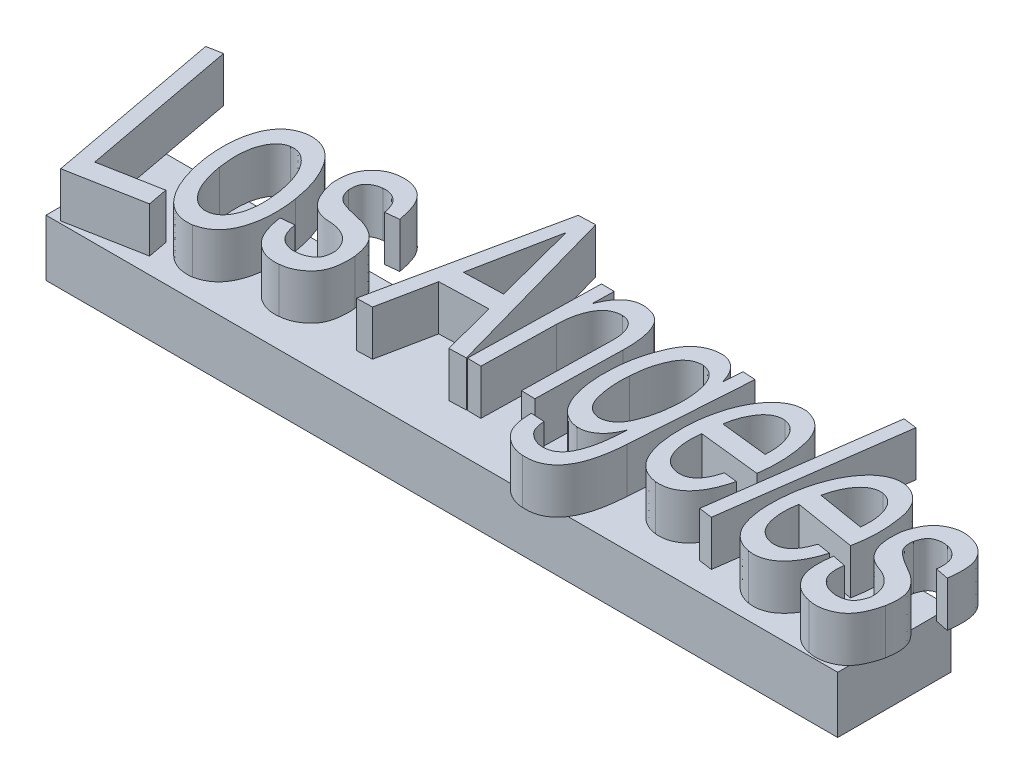
from build123d import *

# Parameters (mm, degrees)
SKETCH1_W           = 88.9
SKETCH1_H           = 12.7
BOSS_EXTRUDE1_DEPTH = 6.35
BOSS_EXTRUDE2_DEPTH = 5.08


with BuildPart() as part:
    # Sketch1 → Boss-Extrude1 (new body)
    with BuildSketch(Plane(origin=(0, 0, 0), x_dir=(1, 0, 0), z_dir=(0, 1, 0))):
        with Locations((44.45, 6.35)):
            Rectangle(SKETCH1_W, SKETCH1_H)
    extrude(amount=BOSS_EXTRUDE1_DEPTH)

    # Sketch4 → Boss-Extrude2 (add)
    with BuildSketch(Plane(origin=(0, 6.35, 0), x_dir=(1, 0, 0), z_dir=(0, 1, 0))):
        Polygon((1.386739329, 0.25954173), (9.796068852, 1.833429402), (9.375962144, 4.077870459), (2.65561001, 2.820091305), (-0.673735645, 20.607286681), (-2.362713034, 20.291178163), align=None)
        with BuildLine():
            add(Edge.make_bspline(
                [(8.537018372, 9.101471274), (8.580799578, 8.834320745), (8.666447796, 8.31169999), (8.847978922, 7.555307868), (9.051668328, 6.840317669), (9.289932152, 6.166912473), (9.550753664, 5.532172303), (9.845524704, 4.939235761), (10.167081842, 4.386690498), (10.520819993, 3.881278636), (10.896307583, 3.424870796), (11.303272628, 3.036955632), (11.734813452, 2.719638512), (12.189889779, 2.474247196), (12.664929288, 2.290790647), (13.167250147, 2.191205733), (13.691001629, 2.149725881), (14.044738343, 2.18151254), (14.224987313, 2.197709651)],
                knots=[0, 0, 0, 0, 0.000811887, 0.001588276, 0.002332023, 0.003041304, 0.003730075, 0.004389466, 0.005026263, 0.005646119, 0.006238379, 0.006796368, 0.007328364, 0.00784026, 0.00834347, 0.008849721, 0.009371437, 0.009913485, 0.009913485, 0.009913485, 0.009913485], degree=3))
            add(Edge.make_bspline(
                [(14.224987313, 2.197709651), (14.401125566, 2.238615432), (14.746515731, 2.318827733), (15.234624609, 2.514433546), (15.675164513, 2.774797862), (16.078257795, 3.085529274), (16.431758706, 3.463957708), (16.741076432, 3.899501531), (17.007630648, 4.393659111), (17.226282332, 4.94235401), (17.407090604, 5.533746991), (17.540687208, 6.160346336), (17.640931937, 6.81520532), (17.698856765, 7.49958692), (17.707877452, 8.214054017), (17.683727802, 8.95702645), (17.618060118, 9.730543059), (17.542728571, 10.253072523), (17.504271866, 10.519823472)],
                knots=[0, 0, 0, 0, 0.000541938, 0.001062689, 0.001569866, 0.002073007, 0.002584287, 0.003117212, 0.003671628, 0.004264478, 0.004886354, 0.005524715, 0.006184754, 0.006872781, 0.007583263, 0.008327091, 0.009102238, 0.009910637, 0.009910637, 0.009910637, 0.009910637], degree=3))
            add(Edge.make_bspline(
                [(17.504271866, 10.519823472), (17.456823974, 10.787305056), (17.363991272, 11.310637856), (17.191976714, 12.07259722), (16.98473705, 12.791799565), (16.750818205, 13.469505457), (16.485800101, 14.106069918), (16.189059262, 14.698624165), (15.865596927, 15.253390939), (15.514341043, 15.761892029), (15.137612559, 16.218948052), (14.729377432, 16.606467195), (14.301031271, 16.927207194), (13.846205173, 17.175498318), (13.369958116, 17.356089757), (12.866697955, 17.45679034), (12.342856636, 17.498034299), (11.989132376, 17.466280341), (11.808889752, 17.450099895)],
                knots=[0, 0, 0, 0, 0.000814914, 0.001594395, 0.002342111, 0.003059189, 0.003744148, 0.004409078, 0.005045874, 0.00566912, 0.00626138, 0.006819369, 0.007353812, 0.00786208, 0.008369156, 0.008875407, 0.009397123, 0.009939172, 0.009939172, 0.009939172, 0.009939172], degree=3))
            add(Edge.make_bspline(
                [(11.808889752, 17.450099895), (11.632757506, 17.409188869), (11.287379122, 17.328966285), (10.799185272, 17.133434646), (10.358956668, 16.872798587), (9.953909129, 16.562462161), (9.605102346, 16.18005007), (9.289872587, 15.747446719), (9.028157167, 15.250407323), (8.805666276, 14.702368387), (8.634065382, 14.108404586), (8.489458897, 13.483199283), (8.399522524, 12.825101673), (8.338359435, 12.138701767), (8.330359914, 11.421333697), (8.354171961, 10.674273143), (8.420224429, 9.89528425), (8.495312921, 9.368584707), (8.53373528, 9.099075504)],
                knots=[0, 0, 0, 0, 0.000541938, 0.001062689, 0.001569866, 0.002073007, 0.002587298, 0.003116867, 0.003674917, 0.004267767, 0.004888449, 0.005527705, 0.006191223, 0.00687925, 0.007593861, 0.008341817, 0.009121079, 0.009937666, 0.009937666, 0.009937666, 0.009937666], degree=3))
            Line((8.53373528, 9.099075504), (8.537018372, 9.101471274))
        make_face()
        with BuildLine():
            add(Edge.make_bspline(
                [(10.144725118, 9.356294064), (10.115424233, 9.571843136), (10.058571206, 9.990076817), (10.003400079, 10.602837522), (9.983466045, 11.181840408), (9.989089233, 11.727983562), (10.030490437, 12.239801485), (10.100396285, 12.717260011), (10.196764032, 13.160412308), (10.329762369, 13.56609616), (10.487294065, 13.932125168), (10.656812235, 14.263213791), (10.859676787, 14.544544865), (11.07173936, 14.792406637), (11.311032357, 14.993412167), (11.568915746, 15.150834977), (11.846457399, 15.271874008), (12.043302509, 15.314047188), (12.143426337, 15.335498269)],
                knots=[0, 0, 0, 0, 0.000652551, 0.001266157, 0.001844737, 0.00238997, 0.002903763, 0.003383884, 0.003836783, 0.004262562, 0.004662242, 0.005031763, 0.005375529, 0.005700338, 0.006008105, 0.006308439, 0.00660454, 0.006911058, 0.006911058, 0.006911058, 0.006911058], degree=3))
            add(Edge.make_bspline(
                [(12.143426337, 15.335498269), (12.245204215, 15.345613133), (12.446126407, 15.365581133), (12.747598151, 15.339006209), (13.04179347, 15.266063017), (13.332375543, 15.152630927), (13.610073245, 14.979353488), (13.889968181, 14.774744796), (14.1570157, 14.514960118), (14.417483808, 14.211812939), (14.667237453, 13.867237589), (14.902590435, 13.479158377), (15.106688134, 13.04380083), (15.310941271, 12.573299008), (15.477243216, 12.054835264), (15.643176883, 11.498979824), (15.781020922, 10.898512043), (15.855406369, 10.481612546), (15.893540159, 10.267888512)],
                knots=[0, 0, 0, 0, 0.000306323, 0.000604719, 0.000902229, 0.001213605, 0.001535884, 0.00188116, 0.002252155, 0.002650403, 0.003079156, 0.003527512, 0.004009619, 0.004520482, 0.005065104, 0.005641499, 0.006260625, 0.006911896, 0.006911896, 0.006911896, 0.006911896], degree=3))
            add(Edge.make_bspline(
                [(15.893540159, 10.267888512), (15.922721417, 10.051950818), (15.979295668, 9.633308364), (16.034642706, 9.020194052), (16.05450007, 8.441190379), (16.049052011, 7.896409973), (16.007491208, 7.387351109), (15.93775907, 6.913962096), (15.840529302, 6.473795491), (15.708926956, 6.070465603), (15.550708607, 5.705169042), (15.376224949, 5.377615372), (15.175853231, 5.0950148), (14.960673379, 4.851092889), (14.722826965, 4.65060892), (14.465016352, 4.490675184), (14.184493125, 4.378571897), (13.988917646, 4.334500183), (13.890450728, 4.312311277)],
                knots=[0, 0, 0, 0, 0.000653663, 0.001267268, 0.001845848, 0.002391082, 0.002900758, 0.003376793, 0.003825663, 0.004251442, 0.004647327, 0.005018805, 0.005362571, 0.005684293, 0.005992061, 0.006292394, 0.006590734, 0.006893246, 0.006893246, 0.006893246, 0.006893246], degree=3))
            add(Edge.make_bspline(
                [(13.890450728, 4.312311277), (13.788661924, 4.302173804), (13.587718161, 4.282161171), (13.286404831, 4.30906388), (12.992848053, 4.380450017), (12.705298848, 4.498257637), (12.422905563, 4.661843184), (12.145520782, 4.869539927), (11.876755457, 5.12413061), (11.616314329, 5.422429956), (11.369697649, 5.765766649), (11.137600081, 6.152453528), (10.923918117, 6.581974729), (10.729849526, 7.054172243), (10.558474658, 7.570160925), (10.396563957, 8.12592547), (10.256185072, 8.725684611), (10.182408665, 9.141364823), (10.144466988, 9.355140545)],
                knots=[0, 0, 0, 0, 0.000306323, 0.000604719, 0.000902229, 0.001209774, 0.001533531, 0.001878807, 0.002246964, 0.002642094, 0.00306508, 0.003513436, 0.003993664, 0.004502938, 0.005043648, 0.005624009, 0.006239114, 0.006890384, 0.006890384, 0.006890384, 0.006890384], degree=3))
            Line((10.144466988, 9.355140545), (10.144725118, 9.356294064))
        make_face(mode=Mode.SUBTRACT)
        with BuildLine():
            add(Edge.make_bspline(
                [(18.480618725, 7.789259508), (18.514447486, 7.573125068), (18.579785704, 7.155674381), (18.72201519, 6.560937906), (18.885181034, 6.017904033), (19.075660632, 5.527613752), (19.289073156, 5.086043585), (19.532562741, 4.696733965), (19.802266343, 4.356310781), (20.101955019, 4.072193989), (20.416974796, 3.830615765), (20.747217038, 3.6328458), (21.083210678, 3.463901632), (21.437354154, 3.345730711), (21.798868553, 3.256577269), (22.173193086, 3.213229975), (22.557856552, 3.203164359), (22.816139767, 3.227282009), (22.948184941, 3.23961196)],
                knots=[0, 0, 0, 0, 0.000656064, 0.001267149, 0.00183285, 0.002355921, 0.00284355, 0.003301915, 0.003730847, 0.004142718, 0.004537568, 0.004919349, 0.005296161, 0.005663181, 0.006036833, 0.006411307, 0.006791364, 0.007188904, 0.007188904, 0.007188904, 0.007188904], degree=3))
            add(Edge.make_bspline(
                [(22.948184941, 3.23961196), (23.071101109, 3.252201794), (23.313397777, 3.277019318), (23.668528044, 3.358559573), (24.01169392, 3.469519847), (24.342993405, 3.613735163), (24.65957016, 3.794784187), (24.964185145, 4.004047476), (25.256562564, 4.247901875), (25.537116334, 4.520666883), (25.7915311, 4.835101739), (26.005358786, 5.196263273), (26.171803753, 5.605033739), (26.305433569, 6.055546722), (26.388640317, 6.552101759), (26.436718112, 7.091810654), (26.451455313, 7.677233272), (26.423601665, 8.081549853), (26.409193071, 8.290701391)],
                knots=[0, 0, 0, 0, 0.000370374, 0.000730094, 0.001090573, 0.001451217, 0.00181186, 0.00218304, 0.002558491, 0.002952757, 0.003355244, 0.00376819, 0.004206932, 0.00467611, 0.005175184, 0.005714377, 0.00630098, 0.006929621, 0.006929621, 0.006929621, 0.006929621], degree=3))
            add(Edge.make_bspline(
                [(26.409193071, 8.290701391), (26.384824053, 8.454822836), (26.337687503, 8.772279963), (26.24037782, 9.227133472), (26.115148695, 9.64196516), (25.973108006, 10.019503255), (25.804095004, 10.356891395), (25.608054059, 10.652019545), (25.393236168, 10.911210013), (25.077993354, 11.200895937), (24.647268912, 11.495249326), (24.100575792, 11.783308702), (23.525702226, 12.006605128), (23.124457728, 12.09542954), (22.923404453, 12.139937163)],
                knots=[0, 0, 0, 0, 0.000497705, 0.000962701, 0.001393894, 0.001796572, 0.002171523, 0.002523187, 0.002857392, 0.003178849, 0.003804458, 0.004415961, 0.005030358, 0.005647401, 0.005647401, 0.005647401, 0.005647401], degree=3))
            add(Edge.make_bspline(
                [(22.923404453, 12.139937163), (22.551723196, 12.22072127), (21.826511443, 12.378344456), (21.034867613, 12.629908345), (20.550480102, 12.851880694), (20.341443846, 12.992649272), (20.154868509, 13.157440629), (19.993047077, 13.34688821), (19.860476523, 13.567294949), (19.748817081, 13.809044519), (19.666137577, 14.079060158), (19.629909037, 14.267900961), (19.61107925, 14.366050984)],
                knots=[0, 0, 0, 0, 0.001141054, 0.002226386, 0.002483149, 0.0027363, 0.002979133, 0.003228208, 0.00348038, 0.003748359, 0.00402529, 0.004324998, 0.004324998, 0.004324998, 0.004324998], degree=3))
            add(Edge.make_bspline(
                [(19.61107925, 14.366050984), (19.60421998, 14.535734016), (19.591454733, 14.851517751), (19.673860631, 15.291197949), (19.832726861, 15.660786375), (20.089490199, 15.936205371), (20.384281072, 16.143626732), (20.700437052, 16.302702642), (21.038099684, 16.409958432), (21.272019302, 16.437643335), (21.39114429, 16.451742041)],
                knots=[0, 0, 0, 0, 0.000508, 0.000945399, 0.001331644, 0.001697267, 0.002058313, 0.002409248, 0.002755412, 0.003114634, 0.003114634, 0.003114634, 0.003114634], degree=3))
            add(Edge.make_bspline(
                [(21.39114429, 16.451742041), (21.517849582, 16.46247575), (21.771237751, 16.483941268), (22.152569608, 16.421722249), (22.522372215, 16.285174816), (22.817207877, 16.115047419), (23.039420562, 15.938223739), (23.194789181, 15.774987557), (23.330051169, 15.580422542), (23.459503331, 15.362610042), (23.56936095, 15.113851688), (23.663929477, 14.838458615), (23.746836124, 14.536327544), (23.789311896, 14.323678486), (23.811371933, 14.213237976)],
                knots=[0, 0, 0, 0, 0.000380326, 0.000760586, 0.001147317, 0.001558171, 0.001775541, 0.001997569, 0.002231384, 0.002484972, 0.002756711, 0.003045374, 0.003357981, 0.003695765, 0.003695765, 0.003695765, 0.003695765], degree=3))
            Line((23.811371933, 14.213237976), (25.343394132, 14.379562481))
            add(Edge.make_bspline(
                [(25.343394132, 14.379562481), (25.305792163, 14.588902955), (25.233355199, 14.992179411), (25.092771659, 15.566873119), (24.93289188, 16.088805275), (24.752509921, 16.558226648), (24.548320542, 16.973978404), (24.313766785, 17.331952861), (24.063443389, 17.642967834), (23.782744524, 17.895677099), (23.4862031, 18.104525606), (23.174607459, 18.273647948), (22.850968647, 18.410624058), (22.515219317, 18.515618396), (22.164419691, 18.580501658), (21.800822284, 18.614308473), (21.421737333, 18.60944233), (21.166567153, 18.580935169), (21.035957299, 18.566343667)],
                knots=[0, 0, 0, 0, 0.00063795, 0.001228956, 0.001773704, 0.002274535, 0.002736292, 0.003160144, 0.003556223, 0.003930445, 0.004289097, 0.004642116, 0.004991908, 0.005342016, 0.00569518, 0.006060126, 0.006435986, 0.006830101, 0.006830101, 0.006830101, 0.006830101], degree=3))
            add(Edge.make_bspline(
                [(21.035957299, 18.566343667), (20.929591546, 18.553327039), (20.719080865, 18.52756556), (20.4102277, 18.451570663), (20.111963249, 18.344850177), (19.825805253, 18.201569633), (19.548765309, 18.032597829), (19.28208091, 17.833318881), (19.029845616, 17.598757805), (18.787320969, 17.33798781), (18.564537847, 17.043503727), (18.381223513, 16.71126259), (18.225237729, 16.348447931), (18.110632429, 15.948732045), (18.034718097, 15.513907088), (17.988881937, 15.045887024), (17.981926757, 14.544622189), (18.002247495, 14.200765398), (18.012737786, 14.023254236)],
                knots=[0, 0, 0, 0, 0.000321245, 0.000635783, 0.000951943, 0.001269637, 0.001594052, 0.001924459, 0.002266459, 0.002625965, 0.002991892, 0.003370983, 0.003761445, 0.004174453, 0.004615154, 0.005084059, 0.005583867, 0.006117224, 0.006117224, 0.006117224, 0.006117224], degree=3))
            add(Edge.make_bspline(
                [(18.012737786, 14.023254236), (18.047341959, 13.871536398), (18.114705366, 13.576189627), (18.23256754, 13.150516548), (18.371459955, 12.756122265), (18.517890182, 12.38778084), (18.682744962, 12.047640755), (18.866690563, 11.737685783), (19.057419217, 11.450693992), (19.270609227, 11.198719834), (19.493743557, 10.972346184), (19.73615953, 10.777856966), (19.990297844, 10.607487992), (20.262448925, 10.469733641), (20.549871351, 10.36338683), (20.850377968, 10.278813008), (21.168102344, 10.230589098), (21.597833375, 10.204852212), (22.119532919, 10.175579436), (22.702707093, 10.051053182), (23.223604259, 9.856995644), (23.680811456, 9.59075717), (24.074273182, 9.250588013), (24.392125393, 8.832956909), (24.656399489, 8.351142379), (24.766267183, 7.993135426), (24.823241851, 7.807481879)],
                knots=[0, 0, 0, 0, 0.000466827, 0.000908765, 0.001324121, 0.00172063, 0.002097442, 0.002456569, 0.002801375, 0.003129762, 0.003445166, 0.003753487, 0.004060478, 0.004361549, 0.004666085, 0.004978691, 0.005296466, 0.0056278, 0.006270211, 0.006861548, 0.007409232, 0.007931275, 0.008440633, 0.008958625, 0.009498213, 0.010079441, 0.010079441, 0.010079441, 0.010079441], degree=3))
            add(Edge.make_bspline(
                [(24.823241851, 7.807481879), (24.829146477, 7.698770393), (24.840433323, 7.490965541), (24.828668834, 7.190816541), (24.790396807, 6.9175959), (24.736959863, 6.667469258), (24.647490561, 6.446584158), (24.539789498, 6.250917377), (24.412668257, 6.075675368), (24.200315922, 5.89582241), (23.919534849, 5.707302928), (23.562828748, 5.537815388), (23.193135856, 5.419734667), (22.939369065, 5.392616547), (22.811892258, 5.378994074)],
                knots=[0, 0, 0, 0, 0.000326512, 0.000624135, 0.000899244, 0.001153705, 0.001389156, 0.001610991, 0.001823279, 0.002033873, 0.002441665, 0.002835151, 0.003215321, 0.003599063, 0.003599063, 0.003599063, 0.003599063], degree=3))
            add(Edge.make_bspline(
                [(22.811892258, 5.378994074), (22.654898547, 5.365805063), (22.344972601, 5.339768246), (21.884512956, 5.410749554), (21.446434396, 5.562484693), (21.103626503, 5.756735857), (20.852635237, 5.963165453), (20.677482336, 6.151733171), (20.519339209, 6.371676197), (20.385216598, 6.628071396), (20.259240566, 6.912310723), (20.159334291, 7.231784156), (20.070977442, 7.580452228), (20.02924229, 7.825018655), (20.007567055, 7.952034724)],
                knots=[0, 0, 0, 0, 0.000471282, 0.000930372, 0.001384906, 0.001856712, 0.002103137, 0.002357363, 0.002626706, 0.002913145, 0.003223891, 0.003558249, 0.003915853, 0.004302253, 0.004302253, 0.004302253, 0.004302253], degree=3))
            Line((20.007567055, 7.952034724), (18.480618725, 7.789259508))
        make_face()
        Polygon((30.572750052, 4.267429982), (32.344312933, 4.323161879), (33.597978139, 10.501182713), (39.05728416, 10.672927949), (40.659812171, 4.584760584), (42.557915258, 4.644473331), (36.875076653, 24.851497055), (34.976973566, 24.791784307), align=None)
        Polygon((35.957835609, 22.367208786), (35.993989953, 22.368346172), (38.443337895, 12.937737083), (34.068662209, 12.800113417), align=None, mode=Mode.SUBTRACT)
        with BuildLine():
            Line((42.641604646, 4.678149128), (44.178507116, 4.645923201))
            Line((44.178507116, 4.645923201), (44.352809454, 12.977103841))
            add(Edge.make_bspline(
                [(44.352809454, 12.977103841), (44.357147261, 13.141699553), (44.365636804, 13.46383062), (44.409154246, 13.93565161), (44.467183341, 14.38465269), (44.558078261, 14.807964468), (44.656796833, 15.209977491), (44.787859242, 15.584899555), (44.929790842, 15.939266754), (45.09972099, 16.264928047), (45.286960903, 16.560775685), (45.493570215, 16.822792419), (45.730060348, 17.039057847), (45.983020581, 17.222766121), (46.262734351, 17.358739507), (46.558035549, 17.465086528), (46.878475582, 17.527359184), (47.099677732, 17.534866029), (47.212830255, 17.538706039)],
                knots=[0, 0, 0, 0, 0.00049382, 0.000966457, 0.001420879, 0.001850982, 0.002264692, 0.002661739, 0.003041392, 0.003408992, 0.003761867, 0.004090824, 0.004406445, 0.00472044, 0.005025199, 0.005336082, 0.005660077, 0.005999372, 0.005999372, 0.005999372, 0.005999372], degree=3))
            add(Edge.make_bspline(
                [(47.212830255, 17.538706039), (47.35512533, 17.526167316), (47.631534881, 17.501810727), (48.011937155, 17.328640791), (48.341588861, 17.068235361), (48.608086094, 16.708534192), (48.817605614, 16.269262023), (48.964546245, 15.754479542), (49.044921883, 15.166491172), (49.048715019, 14.751155274), (49.050716434, 14.532006852)],
                knots=[0, 0, 0, 0, 0.000425799, 0.000827119, 0.001232835, 0.001674773, 0.002156879, 0.002686191, 0.003274361, 0.003931369, 0.003931369, 0.003931369, 0.003931369], degree=3))
            Line((49.050716434, 14.532006852), (48.843458145, 4.548108033))
            Line((48.843458145, 4.548108033), (50.380360616, 4.515882106))
            Line((50.380360616, 4.515882106), (50.583315393, 14.216571893))
            add(Edge.make_bspline(
                [(50.583315393, 14.216571893), (50.587694232, 14.41256896), (50.596226532, 14.794475172), (50.579703092, 15.354644846), (50.537260216, 15.886312821), (50.479482884, 16.390535911), (50.386279255, 16.862850564), (50.274468143, 17.306693326), (50.145844028, 17.724392142), (49.984968011, 18.109386315), (49.79597356, 18.45909533), (49.573039768, 18.769514726), (49.308526232, 19.031317944), (49.012910581, 19.254315916), (48.677797878, 19.429115986), (48.30677856, 19.554669843), (47.903712641, 19.644373537), (47.622195902, 19.663898567), (47.477155459, 19.673958071)],
                knots=[0, 0, 0, 0, 0.000588074, 0.001145879, 0.001680258, 0.002187922, 0.002667439, 0.00312321, 0.003560784, 0.003977288, 0.004372828, 0.004751176, 0.005119147, 0.005485074, 0.005858247, 0.006247483, 0.006657382, 0.007093003, 0.007093003, 0.007093003, 0.007093003], degree=3))
            add(Edge.make_bspline(
                [(47.477155459, 19.673958071), (47.311307654, 19.672129802), (46.985090635, 19.668533657), (46.510647443, 19.552056901), (46.068894165, 19.350798773), (45.662647504, 19.05766137), (45.289763827, 18.680944344), (44.949252662, 18.217987303), (44.639775198, 17.671214291), (44.471594935, 17.26678937), (44.383724564, 17.055486527)],
                knots=[0, 0, 0, 0, 0.000496229, 0.000976065, 0.001452889, 0.001944524, 0.002470198, 0.003036848, 0.003663872, 0.004349926, 0.004349926, 0.004349926, 0.004349926], degree=3))
            Line((44.383724564, 17.055486527), (44.347763817, 17.058995483))
            Line((44.347763817, 17.058995483), (44.396711734, 19.398573608))
            Line((44.396711734, 19.398573608), (42.950215291, 19.428903892))
            Line((42.950215291, 19.428903892), (42.641604646, 4.678149128))
        make_face()
        with BuildLine():
            Line((60.873845465, 18.740904129), (59.430252986, 18.836734921))
            Line((59.430252986, 18.836734921), (59.290273882, 16.729586801))
            Line((59.290273882, 16.729586801), (59.272228976, 16.730784686))
            add(Edge.make_bspline(
                [(59.272228976, 16.730784686), (59.209514223, 16.926428733), (59.089040889, 17.30225562), (58.855819873, 17.823208221), (58.573955434, 18.270138189), (58.250170141, 18.643746143), (57.888580004, 18.93719138), (57.503496232, 19.16393032), (57.08699806, 19.307287175), (56.798229961, 19.34384044), (56.652688612, 19.362263567)],
                knots=[0, 0, 0, 0, 0.000616089, 0.001183491, 0.0017071, 0.002195865, 0.00265965, 0.003098158, 0.003530477, 0.003969783, 0.003969783, 0.003969783, 0.003969783], degree=3))
            add(Edge.make_bspline(
                [(56.652688612, 19.362263567), (56.457980114, 19.355580684), (56.077595055, 19.342524916), (55.529761418, 19.227548795), (55.019202934, 19.046397876), (54.553716417, 18.78045194), (54.122929683, 18.447722556), (53.736694311, 18.036644739), (53.392004899, 17.552659847), (53.098063958, 16.999458366), (52.837699616, 16.407685653), (52.594113153, 15.799044845), (52.389531443, 15.176433028), (52.215085552, 14.540840292), (52.071380902, 13.892849635), (51.954690513, 13.231686217), (51.872042025, 12.557407361), (51.840502385, 12.10313314), (51.824623571, 11.874426169)],
                knots=[0, 0, 0, 0, 0.000583527, 0.001139985, 0.00167174, 0.002202468, 0.002741107, 0.003299096, 0.003888194, 0.00451842, 0.005174701, 0.005827371, 0.006484314, 0.007139592, 0.007803932, 0.008474788, 0.00915304, 0.009840732, 0.009840732, 0.009840732, 0.009840732], degree=3))
            add(Edge.make_bspline(
                [(51.824623571, 11.874426169), (51.811249978, 11.621184299), (51.784951097, 11.123189674), (51.786541933, 10.388618003), (51.81646171, 9.68256657), (51.889117161, 9.004593174), (51.988840743, 8.354243268), (52.130638267, 7.732510588), (52.304936505, 7.139606086), (52.506910479, 6.576736667), (52.747073279, 6.057062839), (53.028088571, 5.594066906), (53.347937051, 5.194877897), (53.701649029, 4.85254571), (54.098966926, 4.580479402), (54.528581777, 4.360097371), (54.999529721, 4.210939755), (55.328771897, 4.163114054), (55.496265848, 4.138783892)],
                knots=[0, 0, 0, 0, 0.000760653, 0.001495807, 0.002202824, 0.002879678, 0.003540349, 0.004175577, 0.004791125, 0.005393452, 0.005968068, 0.006505693, 0.007013961, 0.00749889, 0.007976642, 0.008453179, 0.00894299, 0.0094502, 0.0094502, 0.0094502, 0.0094502], degree=3))
            add(Edge.make_bspline(
                [(55.496265848, 4.138783892), (55.648182313, 4.136984683), (55.951191264, 4.133396025), (56.400896332, 4.235018056), (56.837932159, 4.41656584), (57.260033342, 4.683606976), (57.660621941, 5.036764987), (58.013422865, 5.486368816), (58.332716469, 6.016863949), (58.495912888, 6.413240268), (58.581436579, 6.620962754)],
                knots=[0, 0, 0, 0, 0.000454478, 0.000906491, 0.001371285, 0.001868613, 0.002398182, 0.002965148, 0.003576414, 0.004249465, 0.004249465, 0.004249465, 0.004249465], degree=3))
            Line((58.581436579, 6.620962754), (58.618752509, 6.620970821))
            Line((58.618752509, 6.620970821), (58.554437786, 5.652821684))
            add(Edge.make_bspline(
                [(58.554437786, 5.652821684), (58.538351652, 5.448174209), (58.50695664, 5.0487675), (58.443275185, 4.467375683), (58.354405351, 3.919528356), (58.254315171, 3.404532046), (58.129518561, 2.922020195), (57.985178885, 2.472814759), (57.82519282, 2.053747918), (57.645425796, 1.66985111), (57.443777657, 1.325784165), (57.221759526, 1.024269276), (56.972227021, 0.774044596), (56.699442014, 0.572089218), (56.403388105, 0.416071152), (56.08153785, 0.314906741), (55.739573999, 0.253371477), (55.504791069, 0.255446548), (55.384753653, 0.256507469)],
                knots=[0, 0, 0, 0, 0.000615835, 0.001201914, 0.00175394, 0.002280425, 0.002775277, 0.003248094, 0.003695251, 0.004120168, 0.004518244, 0.004889951, 0.0052404, 0.00557412, 0.005904785, 0.006239143, 0.00658271, 0.006942122, 0.006942122, 0.006942122, 0.006942122], degree=3))
            add(Edge.make_bspline(
                [(55.384753653, 0.256507469), (55.253005976, 0.26940362), (54.985258812, 0.295612112), (54.594356904, 0.430335294), (54.214784718, 0.633667575), (53.847526716, 0.896662975), (53.519767296, 1.243565841), (53.294005352, 1.693837611), (53.150084756, 2.223328782), (53.1341061, 2.605456003), (53.125599181, 2.808897713)],
                knots=[0, 0, 0, 0, 0.000396014, 0.000804809, 0.001229726, 0.001684898, 0.002155527, 0.002645077, 0.003180094, 0.003789236, 0.003789236, 0.003789236, 0.003789236], degree=3))
            Line((53.125599181, 2.808897713), (51.593782679, 2.911633486))
            add(Edge.make_bspline(
                [(51.593782679, 2.911633486), (51.594676147, 2.718936355), (51.59639064, 2.349166178), (51.64833242, 1.815308393), (51.7288309, 1.323397071), (51.843918681, 0.869291709), (51.994139792, 0.454934526), (52.187465852, 0.083674299), (52.40956607, -0.249600989), (52.667870233, -0.54004316), (52.950900262, -0.788587728), (53.238812542, -1.013448023), (53.537970585, -1.206111631), (53.848403646, -1.360638754), (54.16442375, -1.492718783), (54.49028868, -1.586048954), (54.82500864, -1.649970008), (55.051331108, -1.667499801), (55.165859344, -1.676370579)],
                knots=[0, 0, 0, 0, 0.000577819, 0.001108787, 0.00160716, 0.002071955, 0.002512327, 0.002926098, 0.003324731, 0.003710932, 0.004088219, 0.004453352, 0.004806226, 0.005153473, 0.005492467, 0.00583229, 0.006168454, 0.006512839, 0.006512839, 0.006512839, 0.006512839], degree=3))
            add(Edge.make_bspline(
                [(55.165859344, -1.676370579), (55.343509436, -1.681541365), (55.6899754, -1.691625801), (56.196826217, -1.642953476), (56.672992905, -1.53250741), (57.114111103, -1.354777946), (57.529481835, -1.127384981), (57.90875255, -0.834554265), (58.262656317, -0.488408491), (58.572796069, -0.074762915), (58.859470723, 0.390856323), (59.116574988, 0.914474556), (59.336361632, 1.499385281), (59.530843619, 2.140607335), (59.690597375, 2.840467814), (59.816097281, 3.597934658), (59.916274803, 4.413680045), (59.956563028, 4.978332433), (59.977404059, 5.270426169)],
                knots=[0, 0, 0, 0, 0.000532796, 0.001039098, 0.001522952, 0.001993854, 0.002461594, 0.002939043, 0.00342676, 0.003942226, 0.004485532, 0.005065511, 0.005689098, 0.006358044, 0.007074372, 0.007840945, 0.008660586, 0.009538974, 0.009538974, 0.009538974, 0.009538974], degree=3))
            Line((59.977404059, 5.270426169), (60.873845465, 18.740904129))
        make_face()
        with BuildLine():
            add(Edge.make_bspline(
                [(55.731716781, 6.269212119), (55.612246461, 6.288655297), (55.377666203, 6.326832023), (55.050660448, 6.454314959), (54.752368277, 6.625565503), (54.493938739, 6.853492511), (54.256070149, 7.120360551), (54.060754214, 7.44250327), (53.893617882, 7.809708344), (53.722797188, 8.368501505), (53.565321705, 9.118410097), (53.45005242, 10.060728565), (53.411080296, 11.044659944), (53.449055161, 11.71209303), (53.468395929, 12.052019665)],
                knots=[0, 0, 0, 0, 0.000362231, 0.000711241, 0.001046287, 0.001388984, 0.001740211, 0.002114958, 0.002514189, 0.002947828, 0.003864837, 0.00480947, 0.005793132, 0.006814098, 0.006814098, 0.006814098, 0.006814098], degree=3))
            add(Edge.make_bspline(
                [(53.468395929, 12.052019665), (53.498317281, 12.402377735), (53.556141251, 13.079455913), (53.735484184, 14.05070172), (54.001854568, 14.935563795), (54.281434646, 15.61117196), (54.547471817, 16.092614486), (54.770350419, 16.399732005), (55.016875942, 16.660102149), (55.284756791, 16.874254518), (55.580790625, 17.031054621), (55.893250372, 17.150288077), (56.231306369, 17.217324565), (56.463799247, 17.221003506), (56.58247723, 17.222881453)],
                knots=[0, 0, 0, 0, 0.001054522, 0.002037898, 0.002956458, 0.003822525, 0.00422569, 0.004604038, 0.004957516, 0.005298742, 0.005627699, 0.005958338, 0.006299339, 0.00665491, 0.00665491, 0.00665491, 0.00665491], degree=3))
            add(Edge.make_bspline(
                [(56.58247723, 17.222881453), (56.697736165, 17.204892039), (56.923434848, 17.169665381), (57.239678294, 17.049122474), (57.530010355, 16.890831994), (57.792530504, 16.687475948), (58.02220961, 16.434659164), (58.218759313, 16.137331065), (58.396700265, 15.800402136), (58.576469107, 15.280302718), (58.755594844, 14.580406228), (58.885872746, 13.690495098), (58.937185422, 12.750072796), (58.904050018, 12.108399107), (58.887062596, 11.779434299)],
                knots=[0, 0, 0, 0, 0.000349108, 0.000683619, 0.001008953, 0.001338584, 0.001674749, 0.002028709, 0.002405543, 0.002814505, 0.003675981, 0.004569645, 0.005508482, 0.006496125, 0.006496125, 0.006496125, 0.006496125], degree=3))
            add(Edge.make_bspline(
                [(58.887062596, 11.779434299), (58.858554781, 11.427704232), (58.802789612, 10.739672305), (58.621497977, 9.741853068), (58.354027255, 8.808694013), (58.07698977, 8.078406991), (57.810011809, 7.547303698), (57.581975547, 7.20650793), (57.332221663, 6.916265593), (57.058912645, 6.67829814), (56.760329359, 6.49302169), (56.438720492, 6.359137367), (56.092198965, 6.27849194), (55.853258034, 6.270064036), (55.731680482, 6.265775762)],
                knots=[0, 0, 0, 0, 0.00105822, 0.002070022, 0.003036153, 0.003967246, 0.00440872, 0.004816512, 0.00519416, 0.005554331, 0.00589931, 0.006243696, 0.006595359, 0.00695965, 0.00695965, 0.00695965, 0.00695965], degree=3))
            Line((55.731680482, 6.265775762), (55.731716781, 6.269212119))
        make_face(mode=Mode.SUBTRACT)
        with BuildLine():
            add(Edge.make_bspline(
                [(68.234374193, 7.951266073), (68.167690956, 7.728996698), (68.042161513, 7.310580435), (67.792724858, 6.741060323), (67.510620534, 6.265854846), (67.189705108, 5.879858731), (66.820235063, 5.597847222), (66.413190391, 5.409949015), (65.966990894, 5.319122119), (65.66216365, 5.338329088), (65.504967212, 5.348233934)],
                knots=[0, 0, 0, 0, 0.000695687, 0.001309612, 0.001859967, 0.002349151, 0.00280595, 0.003242099, 0.003684346, 0.004155247, 0.004155247, 0.004155247, 0.004155247], degree=3))
            add(Edge.make_bspline(
                [(65.504967212, 5.348233934), (65.382970345, 5.371121488), (65.146117044, 5.415556996), (64.811275009, 5.535499506), (64.502451959, 5.685466345), (64.22813008, 5.88416968), (63.979883204, 6.116029118), (63.77072226, 6.394637057), (63.581981497, 6.704053357), (63.433467901, 7.053888219), (63.305517484, 7.426411352), (63.208291013, 7.819426309), (63.133206537, 8.226235801), (63.08410699, 8.648440771), (63.059948481, 9.086981628), (63.059314447, 9.542073377), (63.088860074, 10.012242678), (63.127220633, 10.329273867), (63.146690789, 10.490185154)],
                knots=[0, 0, 0, 0, 0.000371822, 0.000721881, 0.001063582, 0.00139822, 0.001734181, 0.002078666, 0.002439901, 0.002818992, 0.003216038, 0.003620723, 0.004032242, 0.004456415, 0.004894905, 0.005349214, 0.00582093, 0.006307123, 0.006307123, 0.006307123, 0.006307123], degree=3))
            Line((63.146690789, 10.490185154), (70.104433866, 9.726241112))
            add(Edge.make_bspline(
                [(70.104433866, 9.726241112), (70.133988071, 9.962808289), (70.192823692, 10.433759109), (70.2533596, 11.140309984), (70.270592512, 11.8461069), (70.266021642, 12.549075008), (70.217894858, 13.251868364), (70.1406427, 13.952100463), (70.027795774, 14.650657613), (69.888414577, 15.33792718), (69.706986939, 15.991502566), (69.463333133, 16.583202984), (69.165074224, 17.104126316), (68.805958281, 17.55013294), (68.394765577, 17.930075421), (67.918663285, 18.223371828), (67.392948362, 18.451998144), (67.015649586, 18.540056444), (66.822463147, 18.585144503)],
                knots=[0, 0, 0, 0, 0.000715208, 0.001423815, 0.002126233, 0.002832525, 0.003531986, 0.004238471, 0.004945306, 0.005654058, 0.006341639, 0.006976718, 0.007568921, 0.008135886, 0.008688469, 0.009239645, 0.009805813, 0.010399885, 0.010399885, 0.010399885, 0.010399885], degree=3))
            add(Edge.make_bspline(
                [(66.822463147, 18.585144503), (66.662673376, 18.590925355), (66.348775678, 18.602281501), (65.881719269, 18.54310962), (65.43272332, 18.413098952), (64.998967764, 18.216624121), (64.584454637, 17.952519426), (64.183651136, 17.625845543), (63.799976141, 17.23234783), (63.440441232, 16.771872478), (63.097913576, 16.262732554), (62.789452576, 15.703459297), (62.511541355, 15.099989838), (62.265098844, 14.452720236), (62.050890308, 13.761441276), (61.868749855, 13.026527079), (61.721329368, 12.247081048), (61.647851909, 11.710300597), (61.610300546, 11.435973772)],
                knots=[0, 0, 0, 0, 0.000479107, 0.000941178, 0.001405238, 0.001876593, 0.002364729, 0.002875592, 0.00342466, 0.00400969, 0.004625958, 0.005263785, 0.005923487, 0.006617648, 0.007340035, 0.008093308, 0.008887927, 0.009718495, 0.009718495, 0.009718495, 0.009718495], degree=3))
            add(Edge.make_bspline(
                [(61.610300546, 11.435973772), (61.586619461, 11.158055406), (61.540366945, 10.615241417), (61.523387986, 9.815644904), (61.53272627, 9.05353681), (61.581733233, 8.326766277), (61.669381244, 7.637734761), (61.785091126, 6.982358815), (61.949285205, 6.36688132), (62.138165439, 5.788070335), (62.372844927, 5.258464499), (62.647956191, 4.782244066), (62.973969622, 4.369847778), (63.338833944, 4.014540964), (63.748122936, 3.721640974), (64.200306926, 3.494546198), (64.692497803, 3.319808522), (65.041136655, 3.260121976), (65.219991603, 3.229502227)],
                knots=[0, 0, 0, 0, 0.000836573, 0.001633947, 0.002398112, 0.003122574, 0.003817729, 0.004481182, 0.005117295, 0.005727221, 0.006305918, 0.006852043, 0.00737258, 0.007877887, 0.008375283, 0.008875842, 0.009391771, 0.009935265, 0.009935265, 0.009935265, 0.009935265], degree=3))
            add(Edge.make_bspline(
                [(65.219991603, 3.229502227), (65.350724645, 3.219513502), (65.606701721, 3.199955442), (65.986031223, 3.223841427), (66.353929433, 3.279356151), (66.707800576, 3.382685128), (67.047798899, 3.530665823), (67.373316276, 3.717884299), (67.691029003, 3.94048528), (67.987600701, 4.213383797), (68.272728809, 4.521439515), (68.536261085, 4.872016996), (68.78774152, 5.25752093), (69.009805664, 5.687881747), (69.224182311, 6.153827276), (69.414699343, 6.661393352), (69.594612167, 7.206191917), (69.692334065, 7.586096136), (69.742430627, 7.78085182)],
                knots=[0, 0, 0, 0, 0.000392901, 0.000769305, 0.001137323, 0.001507213, 0.001871645, 0.002247141, 0.002632193, 0.00303281, 0.003453714, 0.003889863, 0.004346961, 0.004832856, 0.005341124, 0.005884948, 0.006458316, 0.007061435, 0.007061435, 0.007061435, 0.007061435], degree=3))
            Line((69.742430627, 7.78085182), (68.234374193, 7.951266073))
        make_face()
        with BuildLine():
            add(Edge.make_bspline(
                [(63.38262975, 12.62195243), (63.432435088, 12.899974772), (63.528426346, 13.43581521), (63.772211813, 14.188636187), (64.075887466, 14.865539763), (64.391939232, 15.365319985), (64.674276096, 15.715499301), (64.902395279, 15.933500679), (65.138988229, 16.118813465), (65.388942757, 16.26497253), (65.650396303, 16.372864127), (65.923892864, 16.444455469), (66.20906843, 16.478335813), (66.40252483, 16.470416167), (66.500316806, 16.466412796)],
                knots=[0, 0, 0, 0, 0.000846504, 0.001631491, 0.002367063, 0.003067108, 0.003398675, 0.003714133, 0.004011527, 0.004298412, 0.004579894, 0.004857379, 0.005144264, 0.005437529, 0.005437529, 0.005437529, 0.005437529], degree=3))
            add(Edge.make_bspline(
                [(66.500316806, 16.466412796), (66.594774378, 16.450288945), (66.780479873, 16.418589128), (67.042884654, 16.316834229), (67.293643042, 16.196590633), (67.521714127, 16.032327861), (67.729778707, 15.835280042), (67.921944442, 15.605730327), (68.092713214, 15.340435136), (68.306349501, 14.943523607), (68.50829903, 14.385516242), (68.676345233, 13.659362462), (68.74866164, 12.864801238), (68.728588756, 12.315701137), (68.718170464, 12.030705479)],
                knots=[0, 0, 0, 0, 0.000286736, 0.000563729, 0.000840783, 0.00111925, 0.001402665, 0.001698795, 0.002014955, 0.002347548, 0.003049431, 0.00378681, 0.004579151, 0.005434167, 0.005434167, 0.005434167, 0.005434167], degree=3))
            Line((68.718170464, 12.030705479), (63.38262975, 12.62195243))
        make_face(mode=Mode.SUBTRACT)
        Polygon((70.291720113, 3.106616921), (71.814909423, 2.897834052), (74.579482594, 23.087857489), (73.056293284, 23.296640359), align=None)
        with BuildLine():
            add(Edge.make_bspline(
                [(80.430561215, 6.275682312), (80.353391623, 6.057229338), (80.207884713, 5.645325938), (79.929833215, 5.089243382), (79.621580295, 4.629673883), (79.280621867, 4.261636806), (78.897085241, 4.00004051), (78.482055211, 3.832255512), (78.030982775, 3.768495618), (77.727335581, 3.803237752), (77.570556547, 3.821175801)],
                knots=[0, 0, 0, 0, 0.000694557, 0.001309621, 0.00185948, 0.002350248, 0.002805026, 0.003240647, 0.003682797, 0.004154784, 0.004154784, 0.004154784, 0.004154784], degree=3))
            add(Edge.make_bspline(
                [(77.570556547, 3.821175801), (77.449906533, 3.84979007), (77.214980185, 3.905506977), (76.884137093, 4.0384737), (76.589538545, 4.215430801), (76.321353115, 4.421783668), (76.08814187, 4.668880914), (75.888313032, 4.952765386), (75.723338983, 5.274833817), (75.589499858, 5.628841357), (75.482957036, 6.007769769), (75.40552601, 6.405854669), (75.352486862, 6.818349201), (75.322444342, 7.244506343), (75.324165034, 7.683186195), (75.349707491, 8.135222886), (75.397555027, 8.603044822), (75.452621427, 8.917980075), (75.480735408, 9.078769297)],
                knots=[0, 0, 0, 0, 0.000371661, 0.000723689, 0.001064389, 0.001399817, 0.001735778, 0.002079544, 0.00243791, 0.002818349, 0.003213198, 0.003617377, 0.00403386, 0.00446024, 0.004898029, 0.005348889, 0.005818212, 0.006307762, 0.006307762, 0.006307762, 0.006307762], degree=3))
            Line((75.480735408, 9.078769297), (82.390881718, 7.950006784))
            add(Edge.make_bspline(
                [(82.390881718, 7.950006784), (82.434283626, 8.182710279), (82.521211445, 8.648782115), (82.610269923, 9.352479906), (82.666795204, 10.058075909), (82.700303885, 10.762215434), (82.683038116, 11.466506234), (82.644231606, 12.169437526), (82.568347261, 12.872242493), (82.465148883, 13.565501831), (82.323279307, 14.228225769), (82.104662752, 14.828597248), (81.837470296, 15.365167862), (81.506303543, 15.833944977), (81.108005833, 16.225980705), (80.653683148, 16.549046165), (80.141295081, 16.805693206), (79.768530906, 16.912545162), (79.577776059, 16.967224582)],
                knots=[0, 0, 0, 0, 0.000710036, 0.001422101, 0.002126592, 0.002833427, 0.00353565, 0.004238978, 0.004945016, 0.005655294, 0.006341596, 0.006973917, 0.007566825, 0.008135278, 0.008687243, 0.009235051, 0.009802092, 0.010396379, 0.010396379, 0.010396379, 0.010396379], degree=3))
            add(Edge.make_bspline(
                [(79.577776059, 16.967224582), (79.419599991, 16.981062149), (79.105897579, 17.008505482), (78.636137319, 16.975553101), (78.180327717, 16.869551794), (77.736339953, 16.697874408), (77.307861931, 16.455543251), (76.889564071, 16.150431218), (76.489684898, 15.774541244), (76.103224621, 15.337240632), (75.738423836, 14.843068471), (75.399601982, 14.300013945), (75.089962309, 13.713584753), (74.812755294, 13.079069646), (74.561594127, 12.401050361), (74.344205913, 11.674826696), (74.152799163, 10.905895079), (74.053157571, 10.374810374), (74.002166303, 10.10302946)],
                knots=[0, 0, 0, 0, 0.000475838, 0.000943706, 0.001405574, 0.00187497, 0.002366779, 0.002878126, 0.003424625, 0.004009757, 0.0046268, 0.005265094, 0.005928342, 0.006614396, 0.007340938, 0.008096122, 0.008887461, 0.009716878, 0.009716878, 0.009716878, 0.009716878], degree=3))
            add(Edge.make_bspline(
                [(74.002166303, 10.10302946), (73.965300405, 9.826584489), (73.893186074, 9.285823374), (73.828727931, 8.48920374), (73.796021036, 7.727060313), (73.811856622, 6.999396548), (73.850701711, 6.30484487), (73.946323823, 5.64649242), (74.065909776, 5.0214459), (74.230441422, 4.435187005), (74.43463353, 3.892588961), (74.683931723, 3.400699579), (74.989342791, 2.972576719), (75.334233663, 2.598966399), (75.727202173, 2.286216434), (76.164816591, 2.031714632), (76.650300093, 1.840162463), (76.993849728, 1.760034569), (77.16993866, 1.718964419)],
                knots=[0, 0, 0, 0, 0.000836543, 0.001636383, 0.002396868, 0.003123868, 0.003819207, 0.004482146, 0.005117977, 0.005727273, 0.006306383, 0.006855001, 0.007376406, 0.007879022, 0.00837568, 0.008877209, 0.009392593, 0.009934531, 0.009934531, 0.009934531, 0.009934531], degree=3))
            add(Edge.make_bspline(
                [(77.16993866, 1.718964419), (77.299131786, 1.702760034), (77.554067185, 1.670784096), (77.935138984, 1.665599779), (78.307054255, 1.706904053), (78.665305466, 1.79490456), (79.01303632, 1.92035783), (79.349919012, 2.085462738), (79.672807757, 2.300030274), (79.987040985, 2.552446988), (80.289550725, 2.844989806), (80.568727336, 3.184039146), (80.839413756, 3.556007439), (81.090500346, 3.971172517), (81.32617169, 4.426605007), (81.543004025, 4.924570031), (81.751652973, 5.459135186), (81.868151361, 5.834481786), (81.927792319, 6.026639216)],
                knots=[0, 0, 0, 0, 0.000390418, 0.000770408, 0.001140298, 0.001509935, 0.001874437, 0.002247541, 0.002632437, 0.003034924, 0.003455503, 0.003892297, 0.004350811, 0.004834595, 0.005346275, 0.005888072, 0.006463325, 0.007066742, 0.007066742, 0.007066742, 0.007066742], degree=3))
            Line((81.927792319, 6.026639216), (80.430561215, 6.275682312))
        make_face()
        with BuildLine():
            add(Edge.make_bspline(
                [(75.830041874, 11.193975915), (75.892819948, 11.468291138), (76.014472261, 11.999863375), (76.29887488, 12.737903764), (76.63734745, 13.399265772), (76.980714835, 13.879380906), (77.281262174, 14.212740984), (77.517784113, 14.421376276), (77.765719321, 14.590176936), (78.02098815, 14.725836727), (78.287499274, 14.82345758), (78.566537677, 14.873465734), (78.853778886, 14.899036917), (79.046425271, 14.8792018), (79.144117522, 14.869143281)],
                knots=[0, 0, 0, 0, 0.000843271, 0.001634103, 0.002365641, 0.003067086, 0.003397415, 0.003710567, 0.004010702, 0.004295198, 0.004576074, 0.00485795, 0.005143673, 0.005437635, 0.005437635, 0.005437635, 0.005437635], degree=3))
            add(Edge.make_bspline(
                [(79.144117522, 14.869143281), (79.237245716, 14.847114641), (79.420622925, 14.803738406), (79.678173382, 14.691528143), (79.922100443, 14.557387674), (80.139649611, 14.380365818), (80.342738171, 14.17654913), (80.517231264, 13.933701407), (80.680865969, 13.664531231), (80.868140741, 13.255052341), (81.04729389, 12.687975072), (81.168313215, 11.951385251), (81.202120657, 11.153667203), (81.152422182, 10.606629993), (81.126556547, 10.321923769)],
                knots=[0, 0, 0, 0, 0.000286528, 0.000564197, 0.000839801, 0.001119093, 0.001402388, 0.001700584, 0.002013654, 0.002346247, 0.003048944, 0.003790394, 0.004579932, 0.005436811, 0.005436811, 0.005436811, 0.005436811], degree=3))
            Line((81.126556547, 10.321923769), (75.830041874, 11.193975915))
        make_face(mode=Mode.SUBTRACT)
        with BuildLine():
            add(Edge.make_bspline(
                [(82.46199998, 5.98301108), (82.428123098, 5.766916792), (82.362809584, 5.350294103), (82.327799439, 4.739381343), (82.311995712, 4.170955995), (82.352363226, 3.643683222), (82.420973436, 3.156655934), (82.54488587, 2.71442046), (82.692805837, 2.306929368), (82.895845369, 1.947774566), (83.123877165, 1.623419673), (83.377012898, 1.33256844), (83.653249507, 1.075291903), (83.954935868, 0.856311433), (84.271953277, 0.66316323), (84.61617597, 0.511985911), (84.979554622, 0.383651357), (85.235516037, 0.332997179), (85.365757697, 0.307222653)],
                knots=[0, 0, 0, 0, 0.000655761, 0.001264287, 0.001834298, 0.002360133, 0.002849038, 0.0033069, 0.003735673, 0.00414605, 0.00454023, 0.004923705, 0.005300721, 0.005669965, 0.006040408, 0.006411955, 0.006795941, 0.007193739, 0.007193739, 0.007193739, 0.007193739], degree=3))
            add(Edge.make_bspline(
                [(85.365757697, 0.307222653), (85.486554659, 0.283006381), (85.725345275, 0.23513582), (86.087800321, 0.202001627), (86.449034067, 0.20587094), (86.808452585, 0.248290684), (87.165016001, 0.32298886), (87.519504047, 0.430741352), (87.869360101, 0.577195242), (88.21873202, 0.752619556), (88.555637083, 0.975092826), (88.868241388, 1.256193232), (89.153551653, 1.592842942), (89.409508926, 1.987608508), (89.645594382, 2.43312614), (89.848192524, 2.937471424), (90.038201102, 3.491592558), (90.132465995, 3.885670718), (90.181432494, 4.090377124)],
                knots=[0, 0, 0, 0, 0.000369406, 0.000730239, 0.001089579, 0.001451262, 0.001814146, 0.002181259, 0.002560912, 0.002950652, 0.003352715, 0.003768071, 0.004207532, 0.004672602, 0.005176962, 0.005717688, 0.006301492, 0.00693257, 0.00693257, 0.00693257, 0.00693257], degree=3))
            add(Edge.make_bspline(
                [(90.181432494, 4.090377124), (90.208877057, 4.253875192), (90.261943607, 4.570013508), (90.29559211, 5.034165314), (90.308634103, 5.467491774), (90.279175213, 5.869814387), (90.218327989, 6.240855095), (90.123231444, 6.581687671), (89.997101889, 6.894040465), (89.777786055, 7.261217657), (89.457249506, 7.673160484), (89.022878578, 8.112343224), (88.538934558, 8.495141364), (88.183876593, 8.699683271), (88.004879648, 8.802799889)],
                knots=[0, 0, 0, 0, 0.00049707, 0.000961131, 0.001394868, 0.001796527, 0.002169289, 0.002521025, 0.002856199, 0.00317638, 0.003800883, 0.004417096, 0.005026014, 0.005645085, 0.005645085, 0.005645085, 0.005645085], degree=3))
            add(Edge.make_bspline(
                [(88.004879648, 8.802799889), (87.834731204, 8.896347336), (87.499867609, 9.080455011), (87.018696777, 9.377521873), (86.570134904, 9.695191115), (86.208723189, 9.961069374), (85.949918456, 10.195802095), (85.791126295, 10.392054778), (85.666147447, 10.605773728), (85.5702393, 10.836220182), (85.502755714, 11.083076547), (85.476820626, 11.34898516), (85.47590078, 11.629993105), (85.498606591, 11.822025915), (85.510310542, 11.921011271)],
                knots=[0, 0, 0, 0, 0.000582473, 0.001146347, 0.00169515, 0.002231266, 0.00249133, 0.002740952, 0.002985326, 0.003231543, 0.003488007, 0.003749804, 0.004030649, 0.004329417, 0.004329417, 0.004329417, 0.004329417], degree=3))
            add(Edge.make_bspline(
                [(85.510310542, 11.921011271), (85.55483636, 12.084527499), (85.637675182, 12.388744075), (85.848295544, 12.781805209), (86.105322923, 13.090617809), (86.434019268, 13.274797752), (86.777678748, 13.381513028), (87.126667382, 13.442449036), (87.481564336, 13.44294969), (87.713453072, 13.400516157), (87.831416233, 13.37892997)],
                knots=[0, 0, 0, 0, 0.000506807, 0.000942897, 0.001329098, 0.001693881, 0.002054359, 0.002406071, 0.002752998, 0.00311222, 0.00311222, 0.00311222, 0.00311222], degree=3))
            add(Edge.make_bspline(
                [(87.831416233, 13.37892997), (87.955689674, 13.351083815), (88.203561949, 13.295542664), (88.546888818, 13.117783855), (88.860216252, 12.879380747), (89.090093045, 12.629396565), (89.250445579, 12.395562763), (89.349220937, 12.1925107), (89.422470946, 11.966943501), (89.47644601, 11.720703067), (89.508171756, 11.451058441), (89.520925242, 11.158336556), (89.50709653, 10.843663267), (89.483339499, 10.628177245), (89.47105851, 10.516783629)],
                knots=[0, 0, 0, 0, 0.000380707, 0.000759348, 0.00114841, 0.001557642, 0.00177185, 0.001997195, 0.002232283, 0.002481803, 0.002752284, 0.003045781, 0.003359912, 0.003696076, 0.003696076, 0.003696076, 0.003696076], degree=3))
            Line((89.47105851, 10.516783629), (90.982373836, 10.219167711))
            add(Edge.make_bspline(
                [(90.982373836, 10.219167711), (91.009814573, 10.429632149), (91.062588234, 10.834394572), (91.097774683, 11.423474012), (91.106498545, 11.969810331), (91.069691248, 12.472776014), (90.996645255, 12.930668784), (90.886832776, 13.344848718), (90.733559112, 13.713298186), (90.546161594, 14.041127457), (90.32340824, 14.327140857), (90.079215647, 14.58373721), (89.813245478, 14.813654082), (89.521975826, 15.012221934), (89.207383068, 15.183712187), (88.865830813, 15.31662913), (88.505210682, 15.432041354), (88.253323235, 15.480942005), (88.124652006, 15.50592184)],
                knots=[0, 0, 0, 0, 0.000636543, 0.001224192, 0.001769378, 0.002274617, 0.002734968, 0.00315878, 0.003556856, 0.00392877, 0.004288111, 0.004641589, 0.00499011, 0.005340656, 0.005697305, 0.006062368, 0.006438591, 0.00683147, 0.00683147, 0.00683147, 0.00683147], degree=3))
            add(Edge.make_bspline(
                [(88.124652006, 15.50592184), (87.914465995, 15.538875576), (87.495736789, 15.604525481), (86.85207837, 15.531585494), (86.216423868, 15.338469054), (85.70437955, 15.071396655), (85.312896298, 14.791191502), (85.033595197, 14.53332764), (84.781273048, 14.227390143), (84.550294653, 13.879958125), (84.344112666, 13.489330445), (84.161999957, 13.05679977), (84.006252668, 12.580886684), (83.922282762, 12.246480741), (83.878928429, 12.073824279)],
                knots=[0, 0, 0, 0, 0.000635791, 0.001266613, 0.001922503, 0.002620768, 0.002987579, 0.003364594, 0.003757495, 0.004174449, 0.004614181, 0.00508057, 0.005580787, 0.006114735, 0.006114735, 0.006114735, 0.006114735], degree=3))
            add(Edge.make_bspline(
                [(83.878928429, 12.073824279), (83.866425473, 11.919711834), (83.842003404, 11.618683414), (83.831199316, 11.176336737), (83.834679637, 10.755344909), (83.876676033, 10.358973333), (83.924599225, 9.983414345), (84.011655001, 9.634662744), (84.105816384, 9.304302754), (84.237433215, 9.002180572), (84.3858823, 8.720104598), (84.554291312, 8.45775567), (84.749728528, 8.222081475), (84.967057379, 8.009065897), (85.206794252, 7.817523641), (85.473566264, 7.654272988), (85.75799998, 7.506604848), (86.162656974, 7.359315454), (86.648243431, 7.170217535), (87.17261562, 6.883563678), (87.605388567, 6.534624828), (87.968341045, 6.148603689), (88.234707514, 5.701997034), (88.417129149, 5.209322551), (88.525046872, 4.669165311), (88.522472578, 4.293254379), (88.521139811, 4.098637287)],
                knots=[0, 0, 0, 0, 0.000463748, 0.00090584, 0.001327189, 0.001725416, 0.002100981, 0.002461624, 0.002802625, 0.00313018, 0.003447955, 0.003758398, 0.004063522, 0.004364338, 0.004670076, 0.00498178, 0.005301322, 0.005629579, 0.006272294, 0.006863992, 0.007413542, 0.007933899, 0.008445296, 0.008961556, 0.009504249, 0.010086825, 0.010086825, 0.010086825, 0.010086825], degree=3))
            add(Edge.make_bspline(
                [(88.521139811, 4.098637287), (88.493651185, 3.993603638), (88.441022618, 3.792510629), (88.342815906, 3.509622453), (88.226371201, 3.259275869), (88.096396513, 3.040655545), (87.949218812, 2.854270022), (87.786534262, 2.700115431), (87.610225703, 2.573301136), (87.353712628, 2.462648581), (87.029106644, 2.36929818), (86.637545233, 2.308733057), (86.248730271, 2.309519021), (85.998474324, 2.362420062), (85.873757697, 2.388783629)],
                knots=[0, 0, 0, 0, 0.000325648, 0.000623473, 0.000896933, 0.001152631, 0.001384836, 0.001606864, 0.001823408, 0.002032253, 0.002441298, 0.002833807, 0.003217927, 0.00359953, 0.00359953, 0.00359953, 0.00359953], degree=3))
            add(Edge.make_bspline(
                [(85.873757697, 2.388783629), (85.72038045, 2.422668611), (85.417448463, 2.489594085), (85.000786233, 2.694195166), (84.628326486, 2.969348081), (84.359654936, 3.256808654), (84.176791224, 3.527318598), (84.072219096, 3.76351807), (83.9812813, 4.019002766), (83.932970682, 4.305087033), (83.89728201, 4.612519672), (83.896519618, 4.947021938), (83.916381193, 5.305726176), (83.948844489, 5.552587069), (83.965660136, 5.680458425)],
                knots=[0, 0, 0, 0, 0.000469832, 0.000927955, 0.001379798, 0.001853228, 0.002100654, 0.002355651, 0.002626006, 0.002911938, 0.003223451, 0.003553883, 0.003913793, 0.004300568, 0.004300568, 0.004300568, 0.004300568], degree=3))
            Line((83.965660136, 5.680458425), (82.46199998, 5.98301108))
        make_face()
    extrude(amount=BOSS_EXTRUDE2_DEPTH)


solid = part.part
